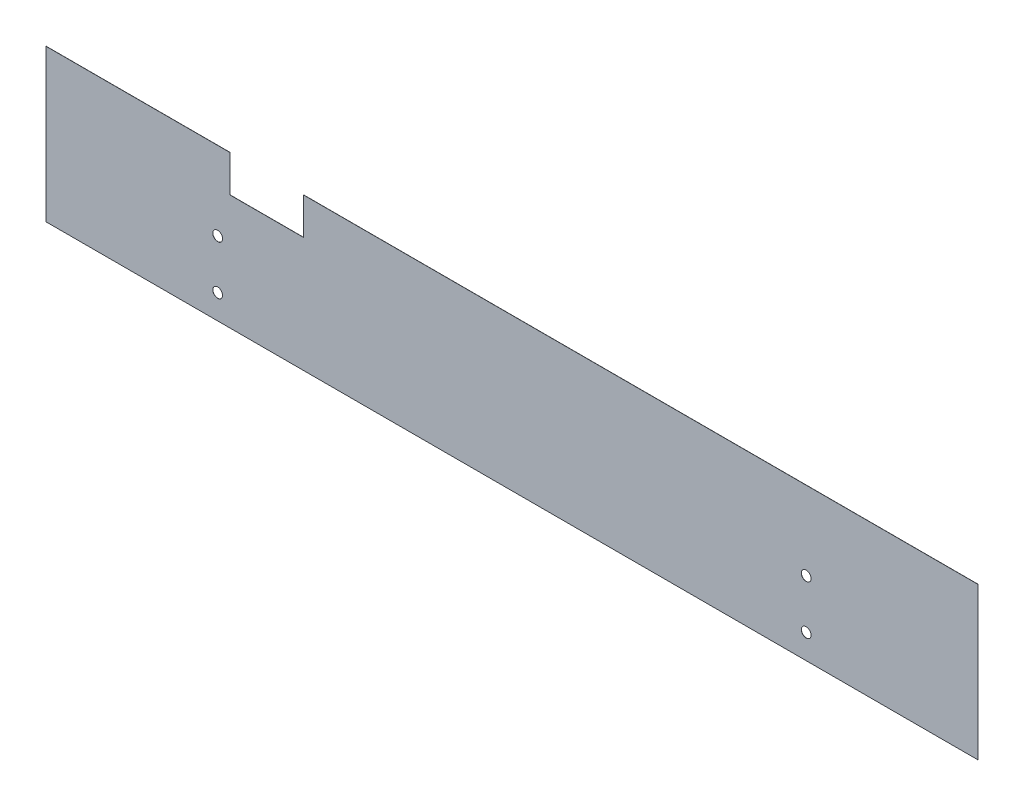
from build123d import *

# Parameters (mm, degrees)
SKETCH1_W             = 380
SKETCH1_H             = 62
BODY_DEPTH            = 0.0625
SKETCH2_R             = 2
MAGNETIC_HOLDER_DEPTH = 0.0625
SKETCH3_W             = 30
SKETCH3_H             = 15
CUT_EXTRUDE2_DEPTH    = 0.0625


with BuildPart() as part:
    # Sketch1 → Body (new body)
    with BuildSketch(Plane.XY):
        Rectangle(SKETCH1_W, SKETCH1_H)
    extrude(amount=BODY_DEPTH)

    # Sketch2 → Magnetic Holder (cut)
    with BuildSketch(Plane.XY.offset(0.0625)):
        with Locations((-120, -1)):
            Circle(SKETCH2_R)
        with Locations((120, -1)):
            Circle(SKETCH2_R)
        with Locations((120, -21)):
            Circle(SKETCH2_R)
        with Locations((-120, -21)):
            Circle(SKETCH2_R)
    extrude(amount=-MAGNETIC_HOLDER_DEPTH, mode=Mode.SUBTRACT)

    # Sketch3 → Cut-Extrude2 (cut)
    with BuildSketch(Plane.XY.offset(0.0625)):
        with Locations((-100, 23.5)):
            Rectangle(SKETCH3_W, SKETCH3_H)
    extrude(amount=-CUT_EXTRUDE2_DEPTH, mode=Mode.SUBTRACT)


solid = part.part
